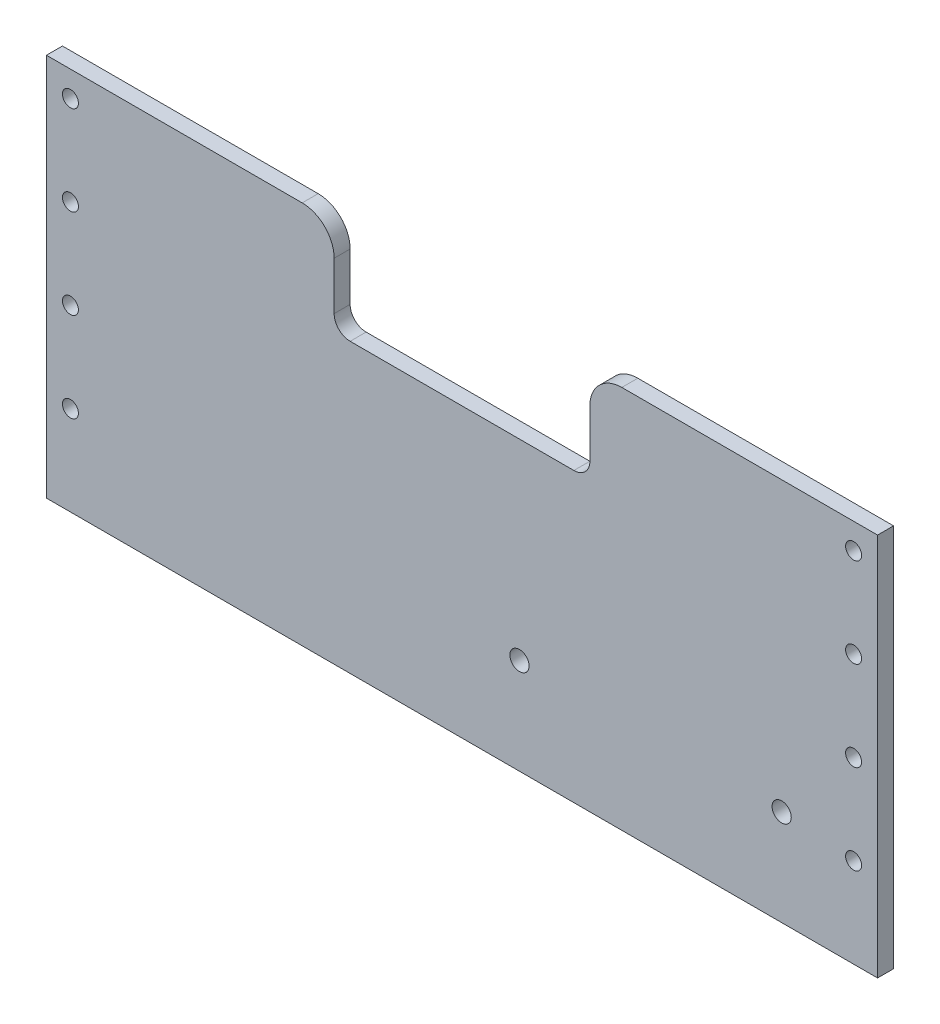
from build123d import *

# Parameters (mm, degrees)
SKETCH5_R           = 1.5875
SKETCH5_R_2         = 1.906243542
BOSS_EXTRUDE2_DEPTH = 3.175


with BuildPart() as part:
    # Sketch5 → Boss-Extrude2 (new body)
    with BuildSketch(Plane.XY):
        with BuildLine():
            Line((-82.55, 17.863023715), (-82.55, -58.336976285))
            Line((-82.55, -58.336976285), (82.55, -58.336976285))
            Line((82.55, -58.336976285), (82.55, 17.863023715))
            Line((82.55, 17.863023715), (31.75, 17.863023715))
            ThreePointArc((31.75, 17.863023715), (27.259871939, 16.003151775), (25.4, 11.513023715))
            Line((25.4, 11.513023715), (25.4, 1.988023715))
            ThreePointArc((25.4, 1.988023715), (24.47006403, -0.257040316), (22.225, -1.186976285))
            Line((22.225, -1.186976285), (-22.225, -1.186976285))
            ThreePointArc((-22.225, -1.186976285), (-24.47006403, -0.257040316), (-25.4, 1.988023715))
            Line((-25.4, 1.988023715), (-25.4, 11.513023715))
            ThreePointArc((-25.4, 11.513023715), (-27.259871939, 16.003151775), (-31.75, 17.863023715))
            Line((-31.75, 17.863023715), (-82.55, 17.863023715))
        make_face()
        with Locations((-77.7875, -40.556976285)):
            Circle(SKETCH5_R, mode=Mode.SUBTRACT)
        with Locations((-77.7875, -22.776976285)):
            Circle(SKETCH5_R, mode=Mode.SUBTRACT)
        with Locations((-77.7875, -4.996976285)):
            Circle(SKETCH5_R, mode=Mode.SUBTRACT)
        with Locations((-77.7875, 12.783023715)):
            Circle(SKETCH5_R, mode=Mode.SUBTRACT)
        with Locations((11.416585625, -39.286976285)):
            Circle(SKETCH5_R_2, mode=Mode.SUBTRACT)
        with Locations((63.5, -39.286976285)):
            Circle(SKETCH5_R_2, mode=Mode.SUBTRACT)
        with Locations((77.7875, 12.783023715)):
            Circle(SKETCH5_R, mode=Mode.SUBTRACT)
        with Locations((77.7875, -4.996976285)):
            Circle(SKETCH5_R, mode=Mode.SUBTRACT)
        with Locations((77.7875, -22.776976285)):
            Circle(SKETCH5_R, mode=Mode.SUBTRACT)
        with Locations((77.7875, -40.556976285)):
            Circle(SKETCH5_R, mode=Mode.SUBTRACT)
    extrude(amount=BOSS_EXTRUDE2_DEPTH)


solid = part.part
